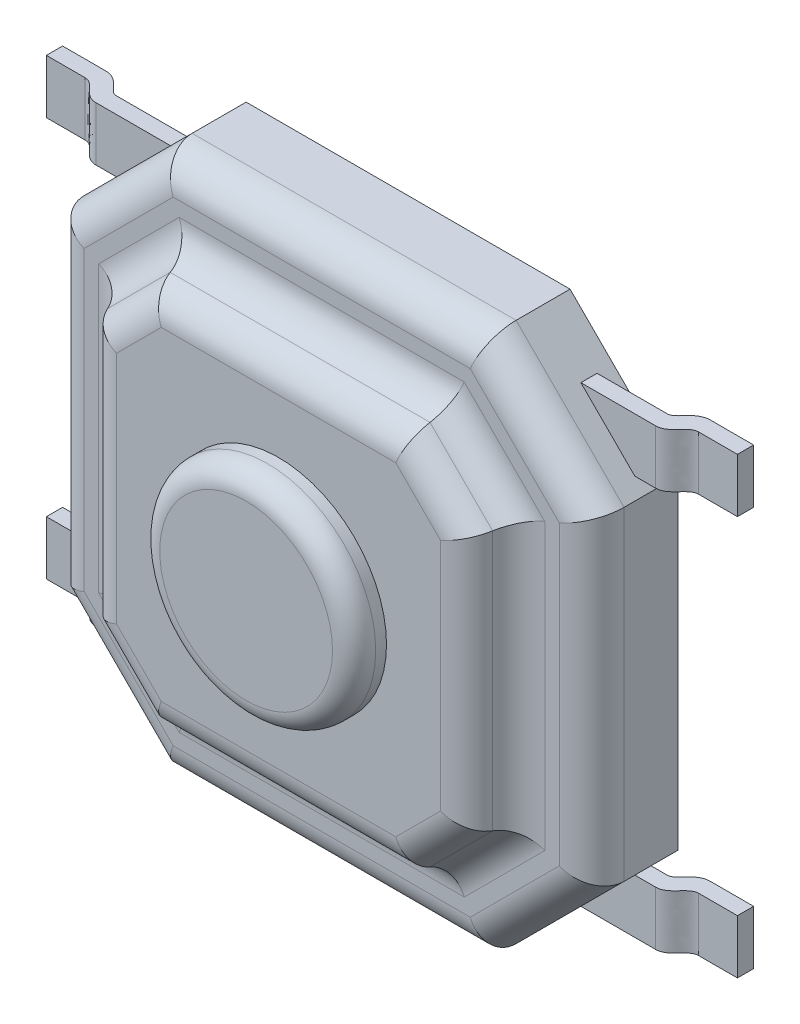
from build123d import *

# Parameters (mm, degrees)
BOSS_EXTRUDE1_DEPTH = 0.8
BOSS_EXTRUDE2_DEPTH = 0.4
SKETCH3_R           = 1
BOSS_EXTRUDE3_DEPTH = 0.3
FILLET1_R           = 0.3
FILLET2_R           = 0.3
FILLET3_R           = 0.3
FILLET4_R           = 0.2
BOSS_EXTRUDE4_DEPTH = 0.25


with BuildPart() as part:
    # Sketch1 → Boss-Extrude1 (new body)
    with BuildSketch(Plane.XY):
        Polygon((-1.5, 2.5), (1.5, 2.5), (2.5, 1.5), (2.5, -1.5), (1.5, -2.5), (-1.5, -2.5), (-2.5, -1.5), (-2.5, 1.5), align=None)
    extrude(amount=BOSS_EXTRUDE1_DEPTH)

    # Sketch2 → Boss-Extrude2 (add)
    with BuildSketch(Plane.XY.offset(0.8)):
        Polygon((-1.210050506, 1.8), (-1.8, 1.210050506), (-1.8, -1.210050506), (-1.210050506, -1.8), (1.210050506, -1.8), (1.8, -1.210050506), (1.8, 1.210050506), (1.210050506, 1.8), align=None)
    extrude(amount=BOSS_EXTRUDE2_DEPTH)

    # Sketch3 → Boss-Extrude3 (add)
    with BuildSketch(Plane.XY.offset(1.2)):
        Circle(SKETCH3_R)
    extrude(amount=BOSS_EXTRUDE3_DEPTH)

    # Fillet1
    fillet1_edges = [part.edges().sort_by_distance(p)[0] for p in [
        (1.505025253, 1.505025253, 1.2),
        (0, 1.8, 1.2),
        (-1.505025253, 1.505025253, 1.2),
        (-1.8, 0, 1.2),
        (-1.505025253, -1.505025253, 1.2),
        (0, -1.8, 1.2),
        (1.505025253, -1.505025253, 1.2),
        (1.8, 0, 1.2),
    ]]
    fillet(fillet1_edges, radius=FILLET1_R)

    # Fillet2
    fillet2_edges = [part.edges().sort_by_distance(p)[0] for p in [
        (-2, 2, 0.8),
        (-2.5, 0, 0.8),
        (-2, -2, 0.8),
        (0, -2.5, 0.8),
        (2, -2, 0.8),
        (2.5, 0, 0.8),
        (2, 2, 0.8),
        (0, 2.5, 0.8),
    ]]
    fillet(fillet2_edges, radius=FILLET2_R)

    # Fillet3
    fillet3_edges = [part.edges().sort_by_distance(p)[0] for p in [
        (0, -1.8, 0.8),
        (1.505025253, -1.505025253, 0.8),
        (1.8, 0, 0.8),
        (1.505025253, 1.505025253, 0.8),
        (0, 1.8, 0.8),
        (-1.505025253, 1.505025253, 0.8),
        (-1.8, 0, 0.8),
        (-1.505025253, -1.505025253, 0.8),
    ]]
    fillet(fillet3_edges, radius=FILLET3_R)

    # Fillet4
    fillet4_edges = [part.edges().sort_by_distance(p)[0] for p in [
        (-1, 0, 1.5),
    ]]
    fillet(fillet4_edges, radius=FILLET4_R)

    # Sketch4 → Boss-Extrude4 (add, symmetric)
    with BuildSketch(Plane(origin=(0, 1.85, 0), x_dir=(1, 0, 0), z_dir=(0, 1, 0))):
        with BuildLine():
            Line((0, -0.15), (-2.55, -0.15))
            add(Edge.make_bspline(
                [(-2.8, 0), (-2.662431202, 0), (-2.630462892, -0.15), (-2.55, -0.15)],
                knots=[0, 0, 0, 0, 1, 1, 1, 1], degree=3))
            Line((-2.8, 0), (-3.2, 0))
            Line((-3.2, 0), (-3.2, -0.15))
            Line((-3.2, -0.15), (-2.841547595, -0.15))
            add(Edge.make_bspline(
                [(-2.591547595, -0.3), (-2.713318055, -0.3), (-2.744365063, -0.15), (-2.841547595, -0.15)],
                knots=[0, 0, 0, 0, 1, 1, 1, 1], degree=3))
            Line((-2.591547595, -0.3), (0, -0.3))
            Line((0, -0.3), (2.591547595, -0.3))
            add(Edge.make_bspline(
                [(2.591547595, -0.3), (2.713318055, -0.3), (2.744365063, -0.15), (2.841547595, -0.15)],
                knots=[0, 0, 0, 0, 1, 1, 1, 1], degree=3))
            Line((2.841547595, -0.15), (3.2, -0.15))
            Line((3.2, -0.15), (3.2, 0))
            Line((3.2, 0), (2.8, 0))
            add(Edge.make_bspline(
                [(2.8, 0), (2.662431202, 0), (2.630462892, -0.15), (2.55, -0.15)],
                knots=[0, 0, 0, 0, 1, 1, 1, 1], degree=3))
            Line((2.55, -0.15), (0, -0.15))
        make_face()
    boss_extrude4 = extrude(amount=BOSS_EXTRUDE4_DEPTH, both=True)

    # Mirror1: Boss-Extrude4 across plane
    add(boss_extrude4.mirror(Plane.ZX))


solid = part.part
